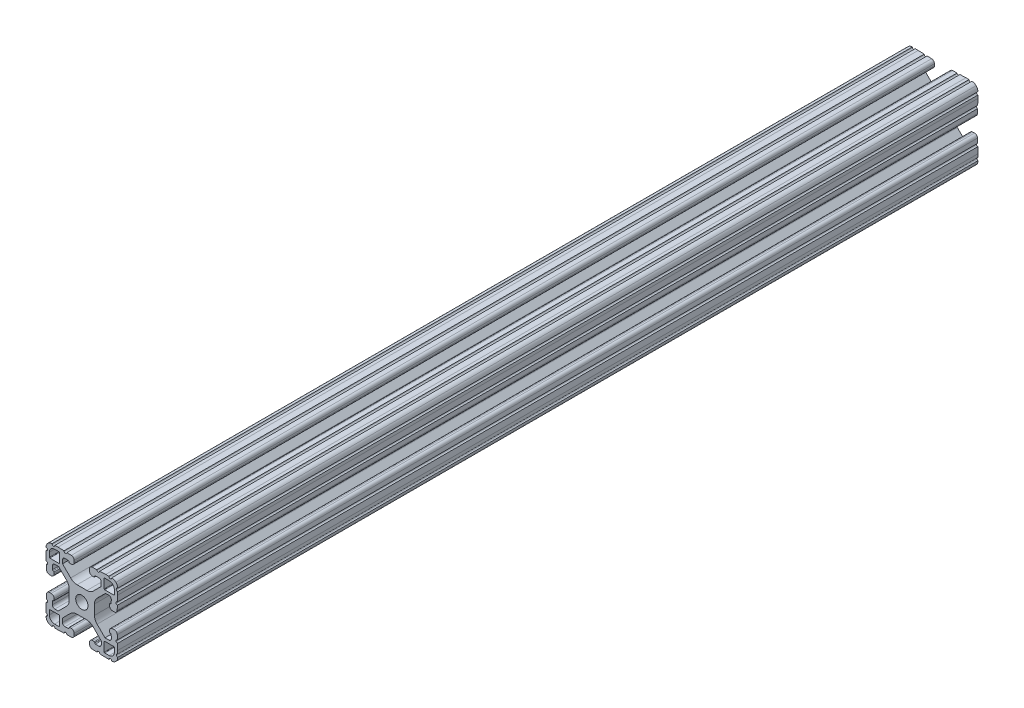
from build123d import *

# Parameters (mm, degrees)
SKETCH1_R           = 3.2639
BOSS_EXTRUDE1_DEPTH = 457.2


with BuildPart() as part:
    # Sketch1 → Boss-Extrude1 (new body)
    with BuildSketch(Plane(origin=(0, 0, -25.4), x_dir=(-1, 0, 0), z_dir=(0, 0, -1))):
        with BuildLine():
            Line((-88.043721549, 91.862643967), (-86.29674679, 91.923648859))
            ThreePointArc((-86.29674679, 91.923648859), (-85.370208675, 91.567983831), (-84.982425017, 90.654422489))
            Line((-84.982425017, 90.654422489), (-84.982425017, 88.800173916))
            Line((-84.982425017, 88.800173916), (-89.306565884, 84.476033049))
            ThreePointArc((-89.306565884, 84.476033049), (-90.866149908, 83.406077005), (-92.719610366, 83.029523439))
            Line((-92.719610366, 83.029523439), (-97.961628589, 83.029523439))
            ThreePointArc((-97.961628589, 83.029523439), (-99.779298356, 83.391080435), (-101.320244378, 84.42070765))
            Line((-101.320244378, 84.42070765), (-105.516001761, 88.616465033))
            Line((-105.516001761, 88.616465033), (-105.516001761, 90.731330035))
            ThreePointArc((-105.516001761, 90.731330035), (-105.128218103, 91.644891377), (-104.201679988, 92.000556406))
            Line((-104.201679988, 92.000556406), (-102.454705229, 91.939551513))
            ThreePointArc((-102.454705229, 91.939551513), (-102.193933359, 91.823448504), (-102.087001761, 91.558783602))
            ThreePointArc((-102.087001761, 91.558783602), (-102.010859042, 91.249291513), (-101.726191901, 91.105946874))
            Line((-101.726191901, 91.105946874), (-100.929727576, 91.078102142))
            ThreePointArc((-100.929727576, 91.078102142), (-99.780779944, 91.519102656), (-99.299905511, 92.651940638))
            Line((-99.299905511, 92.651940638), (-99.299905511, 93.566848638))
            ThreePointArc((-99.299905511, 93.566848638), (-99.741889517, 94.660796975), (-100.819746715, 95.140689345))
            Line((-100.819746715, 95.140689345), (-103.211918901, 95.224224422))
            ThreePointArc((-103.211918901, 95.224224422), (-104.000045777, 94.489281495), (-104.734990687, 95.277406522))
            Line((-104.734990687, 95.277406522), (-107.935905676, 95.389166912))
            Line((-107.935905676, 95.389166912), (-109.561454876, 95.389166912))
            ThreePointArc((-109.561454876, 95.389166912), (-110.323454876, 94.627166912), (-111.085454876, 95.389166912))
            ThreePointArc((-111.085454876, 95.389166912), (-112.308767787, 95.144035599), (-113.343184761, 94.446493225))
            ThreePointArc((-113.343184761, 94.446493225), (-114.04072548, 93.412075135), (-114.285854836, 92.188761832))
            ThreePointArc((-114.285854836, 92.188761832), (-113.523853616, 91.426762441), (-114.285853616, 90.664761832))
            Line((-114.285853616, 90.664761832), (-114.285853616, 89.039212632))
            Line((-114.285853616, 89.039212632), (-114.174093219, 85.838297643))
            ThreePointArc((-114.174093219, 85.838297643), (-113.385968191, 85.103352735), (-114.120911115, 84.315225857))
            Line((-114.120911115, 84.315225857), (-114.037376031, 81.923053667))
            ThreePointArc((-114.037376031, 81.923053667), (-113.55748366, 80.845196472), (-112.463535325, 80.403212468))
            Line((-112.463535325, 80.403212468), (-111.548627325, 80.403212468))
            ThreePointArc((-111.548627325, 80.403212468), (-110.415788905, 80.884087354), (-109.974788872, 82.033035791))
            Line((-109.974788872, 82.033035791), (-110.002634241, 82.829500094))
            ThreePointArc((-110.002634241, 82.829500094), (-110.118742417, 83.090261917), (-110.383401914, 83.197188))
            ThreePointArc((-110.383401914, 83.197188), (-110.693757401, 83.272605688), (-110.837665276, 83.557735272))
            Line((-110.837665276, 83.557735272), (-110.898671566, 85.304709982))
            ThreePointArc((-110.898671566, 85.304709982), (-110.543006925, 86.231248747), (-109.62944523, 86.61903277))
            Line((-109.62944523, 86.61903277), (-107.807161806, 86.61903277))
            Line((-107.807161806, 86.61903277), (-103.364925613, 82.176810793))
            ThreePointArc((-103.364925613, 82.176810793), (-102.335294479, 80.635862907), (-101.973736029, 78.81818963))
            Line((-101.973736029, 78.81818963), (-101.973736029, 73.576034207))
            ThreePointArc((-101.973736029, 73.576034207), (-102.335293752, 71.758362684), (-103.364922926, 70.21741573))
            Line((-103.364922926, 70.21741573), (-107.560683666, 66.021661704))
            Line((-107.560683666, 66.021661704), (-109.652436558, 66.021661704))
            ThreePointArc((-109.652436558, 66.021661704), (-110.565998503, 66.409445617), (-110.921663765, 67.335984343))
            Line((-110.921663765, 67.335984343), (-110.860658873, 69.082959102))
            ThreePointArc((-110.860658873, 69.082959102), (-110.744555864, 69.343730973), (-110.479890961, 69.45066257))
            ThreePointArc((-110.479890961, 69.45066257), (-110.173494703, 69.529390272), (-110.032185196, 69.812424443))
            Line((-110.032185196, 69.812424443), (-110.004340464, 70.608888768))
            ThreePointArc((-110.004340464, 70.608888768), (-110.445340978, 71.7578364), (-111.57817896, 72.238710833))
            Line((-111.57817896, 72.238710833), (-112.49308696, 72.238710833))
            ThreePointArc((-112.49308696, 72.238710833), (-113.587035297, 71.796726827), (-114.066927667, 70.718869629))
            Line((-114.066927667, 70.718869629), (-114.150462744, 68.326697443))
            ThreePointArc((-114.150462744, 68.326697443), (-113.415519817, 67.538570567), (-114.203644843, 66.803625657))
            Line((-114.203644843, 66.803625657), (-114.315405233, 63.602710668))
            Line((-114.315405233, 63.602710668), (-114.315405233, 61.962557497))
            ThreePointArc((-114.315405233, 61.962557497), (-113.701927281, 61.206106537), (-114.333208228, 60.464447842))
            ThreePointArc((-114.333208228, 60.464447842), (-114.113020459, 59.176546471), (-113.392816136, 58.086372941))
            ThreePointArc((-113.392816136, 58.086372941), (-112.358398046, 57.388832223), (-111.135084743, 57.143702867))
            ThreePointArc((-111.135084743, 57.143702867), (-110.373085352, 57.905704086), (-109.611084743, 57.143704086))
            Line((-109.611084743, 57.143704086), (-107.985535543, 57.143704086))
            Line((-107.985535543, 57.143704086), (-104.784620554, 57.255464483))
            ThreePointArc((-104.784620554, 57.255464483), (-104.049675645, 58.04358951), (-103.261548768, 57.308646586))
            Line((-103.261548768, 57.308646586), (-100.869376578, 57.39218167))
            ThreePointArc((-100.869376578, 57.39218167), (-99.791519383, 57.872074041), (-99.349535378, 58.966022376))
            Line((-99.349535378, 58.966022376), (-99.349535378, 59.880930376))
            ThreePointArc((-99.349535378, 59.880930376), (-99.830409811, 61.013768358), (-100.979357443, 61.454768873))
            Line((-100.979357443, 61.454768873), (-101.775821768, 61.42692414))
            ThreePointArc((-101.775821768, 61.42692414), (-102.036583684, 61.310816174), (-102.143509978, 61.046156762))
            ThreePointArc((-102.143509978, 61.046156762), (-102.222494916, 60.740061862), (-102.505377386, 60.598958297))
            Line((-102.505377386, 60.598958297), (-104.252352145, 60.537953405))
            ThreePointArc((-104.252352145, 60.537953405), (-105.17889026, 60.893618433), (-105.566673918, 61.807179775))
            Line((-105.566673918, 61.807179775), (-105.566673918, 63.629462758))
            Line((-105.566673918, 63.629462758), (-101.131142468, 68.064994208))
            ThreePointArc((-101.131142468, 68.064994208), (-99.590196446, 69.094621422), (-97.772526678, 69.456178419))
            Line((-97.772526678, 69.456178419), (-92.530356056, 69.456178419))
            ThreePointArc((-92.530356056, 69.456178419), (-90.712686289, 69.094621422), (-89.171740267, 68.064994208))
            Line((-89.171740267, 68.064994208), (-84.975982884, 63.869236825))
            Line((-84.975982884, 63.869236825), (-84.975982884, 61.781050107))
            ThreePointArc((-84.975982884, 61.781050107), (-85.363766542, 60.867488765), (-86.290304657, 60.511823736))
            Line((-86.290304657, 60.511823736), (-88.037279416, 60.572828629))
            ThreePointArc((-88.037279416, 60.572828629), (-88.298051286, 60.688931638), (-88.404982884, 60.95359654))
            ThreePointArc((-88.404982884, 60.95359654), (-88.466593694, 61.278962759), (-88.759626911, 61.433204782))
            Line((-88.759626911, 61.433204782), (-89.556091237, 61.461049514))
            ThreePointArc((-89.556091237, 61.461049514), (-90.705038868, 61.020049), (-91.185913301, 59.887211018))
            Line((-91.185913301, 59.887211018), (-91.185913301, 58.972303018))
            ThreePointArc((-91.185913301, 58.972303018), (-90.743929295, 57.878354681), (-89.666072098, 57.398462311))
            Line((-89.666072098, 57.398462311), (-87.273899911, 57.314927234))
            ThreePointArc((-87.273899911, 57.314927234), (-86.485773036, 58.049870161), (-85.750828126, 57.261745135))
            Line((-85.750828126, 57.261745135), (-82.549913136, 57.149984745))
            Line((-82.549913136, 57.149984745), (-80.924363936, 57.149984745))
            ThreePointArc((-80.924363936, 57.149984745), (-80.162363936, 57.911984745), (-79.400363936, 57.149984745))
            ThreePointArc((-79.400363936, 57.149984745), (-78.177051025, 57.395116058), (-77.142634052, 58.092658432))
            ThreePointArc((-77.142634052, 58.092658432), (-76.445094372, 59.127074031), (-76.199963977, 60.350384428))
            ThreePointArc((-76.199963977, 60.350384428), (-76.961961268, 61.112385783), (-76.199961268, 61.874384428))
            Line((-76.199961268, 61.874384428), (-76.199961268, 63.499933628))
            Line((-76.199961268, 63.499933628), (-76.311721666, 66.700848617))
            ThreePointArc((-76.311721666, 66.700848617), (-77.099846694, 67.435793525), (-76.364903769, 68.223920403))
            Line((-76.364903769, 68.223920403), (-76.448438853, 70.616092593))
            ThreePointArc((-76.448438853, 70.616092593), (-76.928331225, 71.693949788), (-78.02227956, 72.135933792))
            Line((-78.02227956, 72.135933792), (-78.93718756, 72.135933792))
            ThreePointArc((-78.93718756, 72.135933792), (-80.07002598, 71.655058906), (-80.511026012, 70.506110469))
            Line((-80.511026012, 70.506110469), (-80.483180643, 69.709646166))
            ThreePointArc((-80.483180643, 69.709646166), (-80.367072468, 69.448884343), (-80.102412971, 69.34195826))
            ThreePointArc((-80.102412971, 69.34195826), (-79.796317908, 69.262973649), (-79.655214052, 68.980091239))
            Line((-79.655214052, 68.980091239), (-79.594207761, 67.233116529))
            ThreePointArc((-79.594207761, 67.233116529), (-79.949872402, 66.306577764), (-80.863434097, 65.918793741))
            Line((-80.863434097, 65.918793741), (-82.685717521, 65.918793741))
            Line((-82.685717521, 65.918793741), (-87.121258001, 70.35431293))
            ThreePointArc((-87.121258001, 70.35431293), (-88.150863946, 71.895196205), (-88.512450271, 73.712794894))
            Line((-88.512450271, 73.712794894), (-88.512606864, 78.954950317))
            ThreePointArc((-88.512606864, 78.954950317), (-88.151076291, 80.772698182), (-87.121419968, 82.313710679))
            Line((-87.121419968, 82.313710679), (-82.925659228, 86.509464706))
            Line((-82.925659228, 86.509464706), (-80.837473527, 86.509464706))
            ThreePointArc((-80.837473527, 86.509464706), (-79.923911584, 86.121680793), (-79.568246321, 85.195142068))
            Line((-79.568246321, 85.195142068), (-79.629251214, 83.448167309))
            ThreePointArc((-79.629251214, 83.448167309), (-79.745354223, 83.187395438), (-80.010019125, 83.080463841))
            ThreePointArc((-80.010019125, 83.080463841), (-80.335385344, 83.018853031), (-80.489627367, 82.725819813))
            Line((-80.489627367, 82.725819813), (-80.5174721, 81.929355488))
            ThreePointArc((-80.5174721, 81.929355488), (-80.076471586, 80.780407856), (-78.943633603, 80.299533423))
            Line((-78.943633603, 80.299533423), (-78.028725603, 80.299533423))
            ThreePointArc((-78.028725603, 80.299533423), (-76.934777267, 80.741517429), (-76.454884897, 81.819374627))
            Line((-76.454884897, 81.819374627), (-76.37134982, 84.211546813))
            ThreePointArc((-76.37134982, 84.211546813), (-77.106292747, 84.999673689), (-76.31816772, 85.734618599))
            Line((-76.31816772, 85.734618599), (-76.20640733, 88.935533588))
            Line((-76.20640733, 88.935533588), (-76.20640733, 90.561082788))
            ThreePointArc((-76.20640733, 90.561082788), (-76.96840733, 91.323083398), (-76.206406111, 92.085082788))
            ThreePointArc((-76.206406111, 92.085082788), (-76.451535467, 93.308396091), (-77.149076185, 94.342814181))
            ThreePointArc((-77.149076185, 94.342814181), (-78.183493159, 95.040356555), (-79.40680607, 95.285487868))
            ThreePointArc((-79.40680607, 95.285487868), (-80.16880607, 94.523487868), (-80.93080607, 95.285487868))
            Line((-80.93080607, 95.285487868), (-82.55635527, 95.285487868))
            Line((-82.55635527, 95.285487868), (-85.757270259, 95.173727471))
            ThreePointArc((-85.757270259, 95.173727471), (-86.492215168, 94.385602444), (-87.280342045, 95.120545368))
            Line((-87.280342045, 95.120545368), (-89.672514235, 95.037010285))
            ThreePointArc((-89.672514235, 95.037010285), (-90.75037143, 94.557117913), (-91.192355435, 93.463169578))
            Line((-91.192355435, 93.463169578), (-91.192355435, 92.548261578))
            ThreePointArc((-91.192355435, 92.548261578), (-90.711481002, 91.415423596), (-89.56253337, 90.974423082))
            Line((-89.56253337, 90.974423082), (-88.766069045, 91.002267814))
            ThreePointArc((-88.766069045, 91.002267814), (-88.505307129, 91.11837578), (-88.398380835, 91.383035192))
            ThreePointArc((-88.398380835, 91.383035192), (-88.336765486, 91.708407548), (-88.043721549, 91.862643967))
        make_face()
        with Locations(Location((-95.25, 76.2, 0), (0, 0, 180))):  # turned: the seam where the file's is
            Circle(SKETCH1_R, mode=Mode.SUBTRACT)
        with BuildLine():
            Line((-83.357745393, 88.294108398), (-83.357745393, 93.170908398))
            ThreePointArc((-83.357745393, 93.170908398), (-83.283351492, 93.350512545), (-83.103748154, 93.424908398))
            Line((-83.103748154, 93.424908398), (-80.766975763, 93.424933798))
            ThreePointArc((-80.766975763, 93.424933798), (-78.791299784, 92.606600882), (-77.972945393, 90.630933798))
            Line((-77.972945393, 90.630933798), (-77.972945393, 88.294108398))
            ThreePointArc((-77.972945393, 88.294108398), (-78.047340271, 88.114503276), (-78.226945393, 88.040108398))
            Line((-78.226945393, 88.040108398), (-83.103745393, 88.040108398))
            ThreePointArc((-83.103745393, 88.040108398), (-83.283350516, 88.114503276), (-83.357745393, 88.294108398))
        make_face(mode=Mode.SUBTRACT)
        with BuildLine():
            Line((-83.357745393, 59.229091602), (-83.357745393, 64.105891602))
            ThreePointArc((-83.357745393, 64.105891602), (-83.283350516, 64.285496724), (-83.103745393, 64.359891602))
            Line((-83.103745393, 64.359891602), (-78.226945393, 64.359891602))
            ThreePointArc((-78.226945393, 64.359891602), (-78.047340271, 64.285496724), (-77.972945393, 64.105891602))
            Line((-77.972945393, 64.105891602), (-77.972945393, 61.769066202))
            ThreePointArc((-77.972945393, 61.769066202), (-78.791299784, 59.793399118), (-80.766975763, 58.975066202))
            Line((-80.766975763, 58.975066202), (-83.103748154, 58.975091602))
            ThreePointArc((-83.103748154, 58.975091602), (-83.283351492, 59.049487455), (-83.357745393, 59.229091602))
        make_face(mode=Mode.SUBTRACT)
        with BuildLine():
            Line((-107.142254607, 93.170908398), (-107.142254607, 88.294108398))
            ThreePointArc((-107.142254607, 88.294108398), (-107.216649484, 88.114503276), (-107.396254607, 88.040108398))
            Line((-107.396254607, 88.040108398), (-112.273054607, 88.040108398))
            ThreePointArc((-112.273054607, 88.040108398), (-112.452659729, 88.114503276), (-112.527054607, 88.294108398))
            Line((-112.527054607, 88.294108398), (-112.527054607, 90.630933798))
            ThreePointArc((-112.527054607, 90.630933798), (-111.708700216, 92.606600882), (-109.733024237, 93.424933798))
            Line((-109.733024237, 93.424933798), (-107.396251846, 93.424908398))
            ThreePointArc((-107.396251846, 93.424908398), (-107.216648508, 93.350512545), (-107.142254607, 93.170908398))
        make_face(mode=Mode.SUBTRACT)
        with BuildLine():
            Line((-107.142254607, 64.105891602), (-107.142254607, 59.229091602))
            ThreePointArc((-107.142254607, 59.229091602), (-107.216648508, 59.049487455), (-107.396251846, 58.975091602))
            Line((-107.396251846, 58.975091602), (-109.733024237, 58.975066202))
            ThreePointArc((-109.733024237, 58.975066202), (-111.708700216, 59.793399118), (-112.527054607, 61.769066202))
            Line((-112.527054607, 61.769066202), (-112.527054607, 64.105891602))
            ThreePointArc((-112.527054607, 64.105891602), (-112.452659729, 64.285496724), (-112.273054607, 64.359891602))
            Line((-112.273054607, 64.359891602), (-107.396254607, 64.359891602))
            ThreePointArc((-107.396254607, 64.359891602), (-107.216649484, 64.285496724), (-107.142254607, 64.105891602))
        make_face(mode=Mode.SUBTRACT)
    extrude(amount=-BOSS_EXTRUDE1_DEPTH)


solid = part.part
